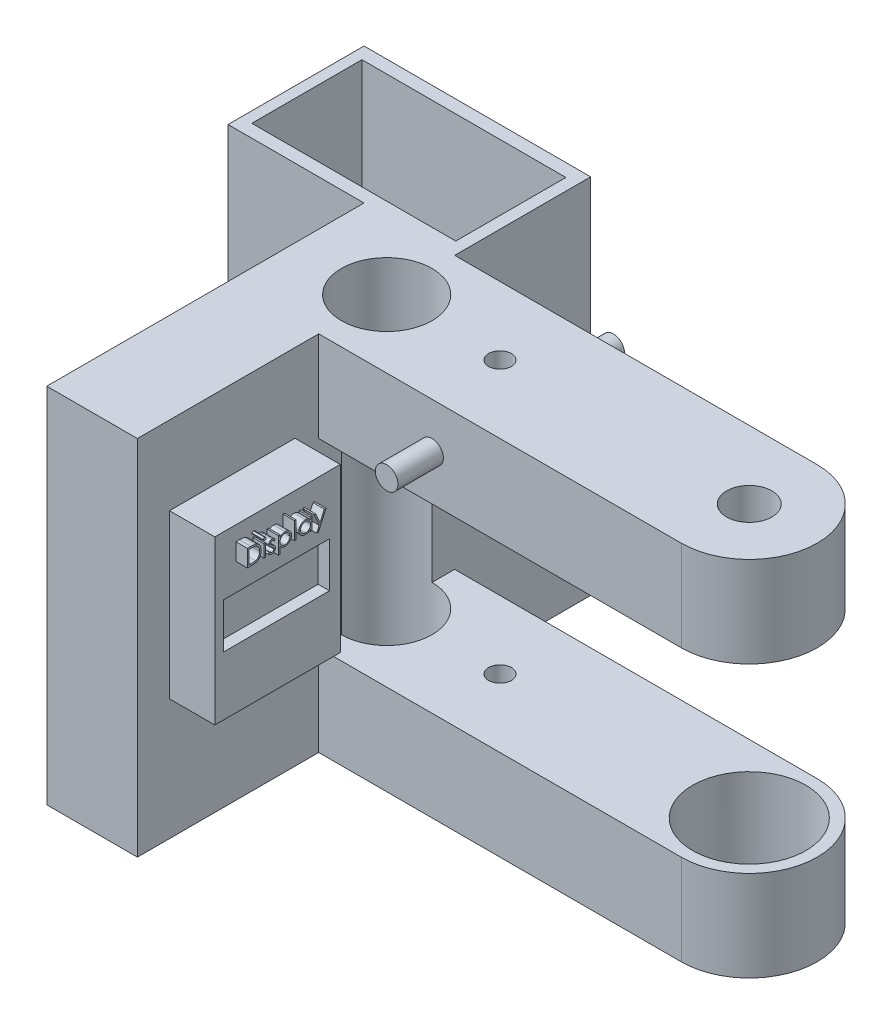
from build123d import *

# Parameters (mm, degrees)
BOSS_EXTRUDE1_DEPTH  = 50.8
SKETCH3_W            = 50.8
SKETCH3_H            = 152.4
BOSS_EXTRUDE2_DEPTH  = 76.2
SKETCH4_W            = 76.2
SKETCH4_H            = 50.8
BOSS_EXTRUDE3_DEPTH  = 254
SKETCH5_R            = 12.7
CUT_EXTRUDE1_DEPTH   = 152.4
SKETCH6_R            = 31.75
CUT_EXTRUDE2_DEPTH   = 254
SKETCH8_R            = 25.4
CUT_EXTRUDE3_DEPTH   = 204.2
SKETCH9_R            = 6.35
CUT_EXTRUDE5_DEPTH   = 204.2
BOSS_EXTRUDE5_DEPTH  = 25.4
BOSS_EXTRUDE6_DEPTH  = 25.4
SKETCH14_W           = 50.8
SKETCH14_H           = 203.2
BOSS_EXTRUDE7_DEPTH  = 101.6
SKETCH15_W           = 70.322125214
SKETCH15_H           = 91.295390628
BOSS_EXTRUDE8_DEPTH  = 25.4
SKETCH16_W           = 0.854807693
SKETCH16_H           = 6.960576923
SKETCH16_W_2         = 0.854807692
SKETCH16_H_2         = 9.769230769
BOSS_EXTRUDE9_DEPTH  = 6.35
SKETCH17_W           = 59.258613474
SKETCH17_H           = 25.299155814
CUT_EXTRUDE6_DEPTH   = 6.35
CUT_EXTRUDE7_DEPTH   = 204.2
SKETCH19_W           = 50.8
SKETCH19_H           = 203.2
BOSS_EXTRUDE10_DEPTH = 76.2
SKETCH20_W           = 76.2
SKETCH20_H           = 203.2
BOSS_EXTRUDE11_DEPTH = 76.2
SKETCH21_W           = 114.3
SKETCH21_H           = 61.717352134
CUT_EXTRUDE9_DEPTH   = 190.5
CUT_EXTRUDE10_DEPTH  = 190.5


with BuildPart() as part:
    # Sketch2 → Boss-Extrude1 (new body)
    with BuildSketch(Plane(origin=(0, 0, 0), x_dir=(1, 0, 0), z_dir=(0, 1, 0))):
        with BuildLine():
            Line((254, 38.1), (0, 38.1))
            Line((0, 38.1), (0, 25.4))
            ThreePointArc((0, 25.4), (17.960512242, 17.960512242), (25.4, 0))
            ThreePointArc((25.4, 0), (17.960512242, -17.960512242), (0, -25.4))
            Line((0, -25.4), (0, -38.1))
            Line((0, -38.1), (254, -38.1))
            Line((254, -38.1), (254, 38.1))
        make_face()
        with BuildLine():
            Line((0, 25.4), (0, 38.1))
            Line((0, 38.1), (-50.8, 38.1))
            Line((-50.8, 38.1), (-50.8, -38.1))
            Line((-50.8, -38.1), (0, -38.1))
            Line((0, -38.1), (0, -25.4))
            ThreePointArc((0, -25.4), (-25.4, 0), (0, 25.4))
        make_face()
    extrude(amount=BOSS_EXTRUDE1_DEPTH)

    # Sketch3 → Boss-Extrude2 (add)
    with BuildSketch(Plane.XY.offset(38.1)):
        with Locations((-25.4, -76.2)):
            Rectangle(SKETCH3_W, SKETCH3_H)
    extrude(amount=-BOSS_EXTRUDE2_DEPTH)

    # Sketch4 → Boss-Extrude3 (add)
    with BuildSketch(Plane(origin=(0, 0, 0), x_dir=(0, 0, -1), z_dir=(1, 0, 0))):
        with Locations((0, -127)):
            Rectangle(SKETCH4_W, SKETCH4_H)
    extrude(amount=BOSS_EXTRUDE3_DEPTH)

    # Sketch5 → Cut-Extrude1 (cut)
    with BuildSketch(Plane(origin=(0, 50.8, 0), x_dir=(1, 0, 0), z_dir=(0, 1, 0))):
        with Locations((203.2, 0)):
            Circle(SKETCH5_R)
    extrude(amount=-CUT_EXTRUDE1_DEPTH, mode=Mode.SUBTRACT)

    # Sketch6 → Cut-Extrude2 (cut)
    with BuildSketch(Plane(origin=(0, -101.6, 0), x_dir=(1, 0, 0), z_dir=(0, 1, 0))):
        with Locations((203.2, 0)):
            Circle(SKETCH6_R)
    extrude(amount=-CUT_EXTRUDE2_DEPTH, mode=Mode.SUBTRACT)

    # Sketch8 → Cut-Extrude3 (cut, through all)
    with BuildSketch(Plane(origin=(0, 50.8, 0), x_dir=(1, 0, 0), z_dir=(0, 1, 0))):
        Circle(SKETCH8_R)
    extrude(amount=-CUT_EXTRUDE3_DEPTH, mode=Mode.SUBTRACT)

    # Sketch9 → Cut-Extrude5 (cut, through all)
    with BuildSketch(Plane(origin=(0, 50.8, 0), x_dir=(1, 0, 0), z_dir=(0, 1, 0))):
        with Locations((63.5, 0)):
            Circle(SKETCH9_R)
    extrude(amount=-CUT_EXTRUDE5_DEPTH, mode=Mode.SUBTRACT)

    # Sketch11 → Boss-Extrude5 (add)
    with BuildSketch(Plane.XY.offset(38.1)):
        with BuildLine():
            ThreePointArc((69.85, 25.4), (63.5, 31.75), (57.15, 25.4))
            Line((57.15, 25.4), (69.85, 25.4))
        make_face()
        with BuildLine():
            Line((69.85, 25.4), (57.15, 25.4))
            ThreePointArc((57.15, 25.4), (63.5, 19.05), (69.85, 25.4))
        make_face()
    extrude(amount=BOSS_EXTRUDE5_DEPTH)

    # Sketch12 → Boss-Extrude6 (add)
    with BuildSketch(Plane(origin=(0, 0, -38.1), x_dir=(-1, 0, 0), z_dir=(0, 0, -1))):
        with BuildLine():
            ThreePointArc((-69.85, 25.4), (-63.5, 19.05), (-57.15, 25.4))
            Line((-57.15, 25.4), (-69.85, 25.4))
        make_face()
        with BuildLine():
            Line((-69.85, 25.4), (-57.15, 25.4))
            ThreePointArc((-57.15, 25.4), (-63.5, 31.75), (-69.85, 25.4))
        make_face()
    extrude(amount=BOSS_EXTRUDE6_DEPTH)

    # Sketch14 → Boss-Extrude7 (add)
    with BuildSketch(Plane.XY.offset(38.1)):
        with Locations((-25.4, -50.8)):
            Rectangle(SKETCH14_W, SKETCH14_H)
    extrude(amount=BOSS_EXTRUDE7_DEPTH)

    # Sketch15 → Boss-Extrude8 (add)
    with BuildSketch(Plane(origin=(0, 0, 0), x_dir=(0, 0, -1), z_dir=(1, 0, 0))):
        with Locations((-86.564796168, -38.887250842)):
            Rectangle(SKETCH15_W, SKETCH15_H)
    extrude(amount=BOSS_EXTRUDE8_DEPTH)

    # Sketch16 → Boss-Extrude9 (add)
    with BuildSketch(Plane(origin=(25.4, 0, 0), x_dir=(0, 0, -1), z_dir=(1, 0, 0))):
        with BuildLine():
            Line((-109.85696619, -11.072266016), (-109.85696619, -1.547266016))
            Line((-109.85696619, -1.547266016), (-107.933648882, -1.547266016))
            add(Edge.make_bspline(
                [(-107.933648882, -1.547266016), (-107.766365422, -1.548470438), (-107.443174646, -1.550797377), (-106.976143628, -1.565551305), (-106.544024961, -1.591651073), (-106.148239823, -1.629668141), (-105.787701667, -1.676348896), (-105.463420026, -1.734860711), (-105.173718123, -1.803952803), (-104.995547717, -1.86285935), (-104.911293113, -1.890715535)],
                knots=[0, 0, 0, 0, 0.000501851, 0.000969573, 0.001401619, 0.001800325, 0.002162196, 0.002491914, 0.002788554, 0.003054677, 0.003054677, 0.003054677, 0.003054677], degree=3))
            add(Edge.make_bspline(
                [(-104.911293113, -1.890715535), (-104.801089573, -1.932709098), (-104.583181542, -2.01574395), (-104.272919302, -2.172379313), (-103.980840992, -2.349852111), (-103.705380319, -2.54839628), (-103.452829499, -2.773633543), (-103.213322294, -3.01599604), (-102.99665651, -3.284297166), (-102.79824179, -3.572972669), (-102.619346889, -3.878621897), (-102.463846752, -4.200662443), (-102.334704099, -4.537458845), (-102.227498246, -4.888074498), (-102.14300753, -5.253280354), (-102.085362415, -5.633501661), (-102.047341364, -6.027235741), (-102.043520339, -6.294410532), (-102.041581575, -6.429973347)],
                knots=[0, 0, 0, 0, 0.000353608, 0.000699197, 0.00104083, 0.00137821, 0.001716199, 0.002054872, 0.002399359, 0.002749199, 0.003104922, 0.003460788, 0.003820798, 0.004185955, 0.004559938, 0.00494422, 0.005338947, 0.005745524, 0.005745524, 0.005745524, 0.005745524], degree=3))
            add(Edge.make_bspline(
                [(-102.041581575, -6.429973347), (-102.043293265, -6.547705718), (-102.046666329, -6.779709651), (-102.076953967, -7.121632374), (-102.120976667, -7.45341145), (-102.189132662, -7.773466962), (-102.271870931, -8.084603041), (-102.377909085, -8.383503649), (-102.4993814, -8.67291073), (-102.641031427, -8.948911147), (-102.796537624, -9.210395181), (-102.963420368, -9.456890011), (-103.141501661, -9.684878294), (-103.332479633, -9.895050445), (-103.533886347, -10.087089626), (-103.747040418, -10.262600039), (-103.972491864, -10.418147521), (-104.209230902, -10.559844437), (-104.464163797, -10.68345269), (-104.742119261, -10.788037217), (-105.044282681, -10.874705505), (-105.369912378, -10.9470163), (-105.719570985, -11.004376674), (-106.093601314, -11.042820642), (-106.491428695, -11.068818266), (-106.764603695, -11.071094451), (-106.905208378, -11.072266016)],
                knots=[0, 0, 0, 0, 0.000353119, 0.000695857, 0.001029112, 0.001356547, 0.00167685, 0.001994264, 0.002307191, 0.002617805, 0.002924094, 0.003219398, 0.00351025, 0.003791207, 0.004070572, 0.004344443, 0.004618619, 0.00489153, 0.005171436, 0.005467338, 0.005781327, 0.006113701, 0.006467535, 0.006843654, 0.007241303, 0.007663052, 0.007663052, 0.007663052, 0.007663052], degree=3))
            Line((-106.905208378, -11.072266016), (-109.85696619, -11.072266016))
        make_face()
        with BuildLine():
            Line((-109.002158498, -10.095342939), (-107.908844195, -10.095342939))
            add(Edge.make_bspline(
                [(-107.908844195, -10.095342939), (-107.751740557, -10.094667762), (-107.449572727, -10.09336915), (-107.015074892, -10.081973976), (-106.618074534, -10.063354132), (-106.258515284, -10.037296242), (-105.936600153, -10.00281951), (-105.651656377, -9.964379596), (-105.404617995, -9.916489391), (-105.255131456, -9.873079995), (-105.186052729, -9.853020222)],
                knots=[0, 0, 0, 0, 0.000471305, 0.000906491, 0.001303825, 0.001663532, 0.001987817, 0.002274926, 0.002526015, 0.002741726, 0.002741726, 0.002741726, 0.002741726], degree=3))
            add(Edge.make_bspline(
                [(-105.186052729, -9.853020222), (-105.099107543, -9.82239991), (-104.927293856, -9.761890652), (-104.679967475, -9.651515874), (-104.44930734, -9.520772813), (-104.231293629, -9.375442338), (-104.029018945, -9.210398576), (-103.840086171, -9.029230385), (-103.664875698, -8.831015747), (-103.50519776, -8.616000679), (-103.362300161, -8.385523449), (-103.238553458, -8.141849909), (-103.130100361, -7.887649947), (-103.044977906, -7.619020022), (-102.978260494, -7.338361656), (-102.931003736, -7.045655104), (-102.901572236, -6.74095503), (-102.898139296, -6.533712463), (-102.896389267, -6.428065295)],
                knots=[0, 0, 0, 0, 0.000276477, 0.00054635, 0.000811185, 0.001071023, 0.001331471, 0.001593271, 0.001855515, 0.002124171, 0.002395799, 0.002668016, 0.002943365, 0.003223953, 0.003512277, 0.003808081, 0.004112808, 0.004429689, 0.004429689, 0.004429689, 0.004429689], degree=3))
            add(Edge.make_bspline(
                [(-102.896389267, -6.428065295), (-102.897786142, -6.316667752), (-102.900530315, -6.097826293), (-102.935022546, -5.776723044), (-102.985427636, -5.467893559), (-103.058317524, -5.171317184), (-103.151202273, -4.886415312), (-103.267120548, -4.614763645), (-103.399563276, -4.353493251), (-103.557143072, -4.108634442), (-103.729724079, -3.877059623), (-103.921252451, -3.664910889), (-104.128685284, -3.471704972), (-104.349760125, -3.294432985), (-104.590707516, -3.140226839), (-104.845851489, -3.002286657), (-105.118935066, -2.885221981), (-105.308925331, -2.82295879), (-105.40547881, -2.791316497)],
                knots=[0, 0, 0, 0, 0.000334046, 0.000656235, 0.000967722, 0.001272228, 0.001571507, 0.001865644, 0.002157495, 0.002449153, 0.002738032, 0.003023099, 0.00330524, 0.003587735, 0.003871938, 0.004162188, 0.004457073, 0.004761795, 0.004761795, 0.004761795, 0.004761795], degree=3))
            add(Edge.make_bspline(
                [(-105.40547881, -2.791316497), (-105.485355859, -2.769228218), (-105.655196379, -2.722262477), (-105.932345206, -2.67103057), (-106.244262149, -2.625842612), (-106.59233205, -2.587584662), (-106.976158142, -2.560132738), (-107.396035621, -2.539527946), (-107.852145974, -2.52563061), (-108.168328441, -2.524681629), (-108.332431935, -2.524189093)],
                knots=[0, 0, 0, 0, 0.000248523, 0.000528429, 0.000844683, 0.001194039, 0.001578624, 0.00199892, 0.00245514, 0.002947432, 0.002947432, 0.002947432, 0.002947432], degree=3))
            Line((-108.332431935, -2.524189093), (-109.002158498, -2.524189093))
            Line((-109.002158498, -2.524189093), (-109.002158498, -10.095342939))
        make_face(mode=Mode.SUBTRACT)
        with BuildLine():
            add(Edge.make_bspline(
                [(-100.030493834, -1.180919862), (-99.977449611, -1.183380448), (-99.873578833, -1.188198748), (-99.723374297, -1.229459625), (-99.586603429, -1.299399484), (-99.465288313, -1.393233472), (-99.361188536, -1.503585886), (-99.288306745, -1.632203236), (-99.241464439, -1.771155674), (-99.235807799, -1.868079595), (-99.232927729, -1.917428275)],
                knots=[0, 0, 0, 0, 0.000158931, 0.000311217, 0.000463108, 0.000616904, 0.000769513, 0.000914826, 0.001057228, 0.001204939, 0.001204939, 0.001204939, 0.001204939], degree=3))
            add(Edge.make_bspline(
                [(-99.232927729, -1.917428275), (-99.235872749, -1.965495924), (-99.241694707, -2.060519978), (-99.288270564, -2.197063498), (-99.361809654, -2.323893727), (-99.46522156, -2.434031874), (-99.586621117, -2.52781399), (-99.723369598, -2.597767601), (-99.873580069, -2.639024832), (-99.977450029, -2.643843634), (-100.030493834, -2.646304477)],
                knots=[0, 0, 0, 0, 0.000143916, 0.000284504, 0.000428167, 0.000580775, 0.000734572, 0.000886463, 0.001038749, 0.00119768, 0.00119768, 0.00119768, 0.00119768], degree=3))
            add(Edge.make_bspline(
                [(-100.030493834, -2.646304477), (-100.082931069, -2.643937596), (-100.184993295, -2.63933077), (-100.332948773, -2.596958079), (-100.468553448, -2.527790052), (-100.590105164, -2.434645934), (-100.691424475, -2.32321732), (-100.765170632, -2.197140899), (-100.811638921, -2.060500271), (-100.817475375, -1.965489305), (-100.820427729, -1.917428275)],
                knots=[0, 0, 0, 0, 0.000157029, 0.000305637, 0.000457528, 0.000611325, 0.000762652, 0.000906314, 0.001046903, 0.001190819, 0.001190819, 0.001190819, 0.001190819], degree=3))
            add(Edge.make_bspline(
                [(-100.820427729, -1.917428275), (-100.817540057, -1.868086463), (-100.811868488, -1.771176031), (-100.765135801, -1.632124548), (-100.692038752, -1.504267747), (-100.590038076, -1.392619781), (-100.468571302, -1.299423276), (-100.33294416, -1.230269105), (-100.184994514, -1.187892817), (-100.082931483, -1.183286488), (-100.030493834, -1.180919862)],
                knots=[0, 0, 0, 0, 0.000147711, 0.000290114, 0.000435427, 0.000586753, 0.00074055, 0.000892441, 0.001041049, 0.001198078, 0.001198078, 0.001198078, 0.001198078], degree=3))
        make_face()
        with Locations((-100.026677729, -7.591977554)):
            Rectangle(SKETCH16_W, SKETCH16_H)
        with BuildLine():
            Line((-94.226196959, -4.979853155), (-94.806245036, -5.577073708))
            add(Edge.make_bspline(
                [(-94.806245036, -5.577073708), (-94.856293478, -5.519071503), (-94.952780982, -5.407250079), (-95.105810941, -5.257742777), (-95.258275176, -5.132184393), (-95.40808659, -5.026178602), (-95.559012308, -4.946034853), (-95.709281207, -4.887538122), (-95.859048874, -4.851338208), (-95.959159441, -4.846672486), (-96.008318354, -4.8443814)],
                knots=[0, 0, 0, 0, 0.00022976, 0.00044295, 0.000640837, 0.00082185, 0.000992565, 0.001152022, 0.001304761, 0.001452127, 0.001452127, 0.001452127, 0.001452127], degree=3))
            add(Edge.make_bspline(
                [(-96.008318354, -4.8443814), (-96.068569122, -4.84730659), (-96.187134106, -4.85306295), (-96.357021512, -4.910521643), (-96.514729999, -4.99871971), (-96.651228637, -5.123819926), (-96.766855823, -5.267414115), (-96.851257341, -5.427968399), (-96.902871911, -5.600637718), (-96.909416217, -5.720461831), (-96.912735421, -5.781235367)],
                knots=[0, 0, 0, 0, 0.000180177, 0.000354563, 0.000532299, 0.000718801, 0.000906237, 0.001082905, 0.00125982, 0.001441896, 0.001441896, 0.001441896, 0.001441896], degree=3))
            add(Edge.make_bspline(
                [(-96.912735421, -5.781235367), (-96.909712425, -5.836241001), (-96.903674954, -5.94609721), (-96.856739348, -6.108152931), (-96.781992395, -6.266151013), (-96.712132795, -6.362932922), (-96.676136863, -6.412800872)],
                knots=[0, 0, 0, 0, 0.000164801, 0.000329137, 0.000502392, 0.000686557, 0.000686557, 0.000686557, 0.000686557], degree=3))
            add(Edge.make_bspline(
                [(-96.676136863, -6.412800872), (-96.654464784, -6.439428919), (-96.608338494, -6.496103362), (-96.521773893, -6.574763134), (-96.423741224, -6.661691689), (-96.305849108, -6.748605509), (-96.173176668, -6.840131847), (-96.022846901, -6.932666223), (-95.85963057, -7.033262265), (-95.742779757, -7.097064622), (-95.68204131, -7.130228756)],
                knots=[0, 0, 0, 0, 0.000102858, 0.00021892, 0.000350133, 0.000495909, 0.000657857, 0.000833616, 0.001025373, 0.001232939, 0.001232939, 0.001232939, 0.001232939], degree=3))
            add(Edge.make_bspline(
                [(-95.68204131, -7.130228756), (-95.607981504, -7.17171667), (-95.464922345, -7.251857659), (-95.261651314, -7.376253352), (-95.077173724, -7.499891728), (-94.909926514, -7.621450524), (-94.763127734, -7.744330828), (-94.632323487, -7.863822652), (-94.520776365, -7.983536412), (-94.458308893, -8.067174386), (-94.428450565, -8.107151833)],
                knots=[0, 0, 0, 0, 0.000254652, 0.000491903, 0.000714697, 0.000920775, 0.001111819, 0.001288692, 0.001452085, 0.001601693, 0.001601693, 0.001601693, 0.001601693], degree=3))
            add(Edge.make_bspline(
                [(-94.428450565, -8.107151833), (-94.378891916, -8.187885973), (-94.280261005, -8.348561894), (-94.176688151, -8.613134901), (-94.116652689, -8.893742768), (-94.108319075, -9.085691167), (-94.104081575, -9.18329366)],
                knots=[0, 0, 0, 0, 0.000283762, 0.000564738, 0.000847658, 0.001140344, 0.001140344, 0.001140344, 0.001140344], degree=3))
            add(Edge.make_bspline(
                [(-94.104081575, -9.18329366), (-94.106039735, -9.252061837), (-94.109898503, -9.387577041), (-94.136726528, -9.587152542), (-94.182868285, -9.77801873), (-94.245716286, -9.962246612), (-94.33058233, -10.136306298), (-94.430044549, -10.304589233), (-94.549446988, -10.463455159), (-94.685767088, -10.612695472), (-94.835025183, -10.749000256), (-94.994245459, -10.868808302), (-95.163623991, -10.968342748), (-95.341950501, -11.050707723), (-95.529630159, -11.116207768), (-95.726692311, -11.161553657), (-95.932510564, -11.188693814), (-96.072473114, -11.192461567), (-96.143790108, -11.1943814)],
                knots=[0, 0, 0, 0, 0.00020629, 0.000406518, 0.000602741, 0.000794631, 0.000989215, 0.001182607, 0.001380282, 0.00158423, 0.001788177, 0.001985852, 0.002180884, 0.002376383, 0.002574306, 0.0027761, 0.002982002, 0.003195917, 0.003195917, 0.003195917, 0.003195917], degree=3))
            add(Edge.make_bspline(
                [(-96.143790108, -11.1943814), (-96.24003935, -11.191679837), (-96.431200458, -11.186314249), (-96.713928908, -11.135951326), (-96.990210402, -11.057586718), (-97.257954179, -10.94950264), (-97.511172532, -10.813021057), (-97.742850262, -10.649565543), (-97.953792171, -10.464535622), (-98.073856902, -10.322714057), (-98.133889267, -10.251803275)],
                knots=[0, 0, 0, 0, 0.00028852, 0.000573031, 0.000858711, 0.001148898, 0.001437468, 0.001719615, 0.001998021, 0.002276427, 0.002276427, 0.002276427, 0.002276427], degree=3))
            Line((-98.133889267, -10.251803275), (-97.56719756, -9.6068814))
            add(Edge.make_bspline(
                [(-97.56719756, -9.6068814), (-97.513388351, -9.664996867), (-97.409071062, -9.777662485), (-97.242244179, -9.927679441), (-97.072483094, -10.0534129), (-96.901482983, -10.158578194), (-96.726712584, -10.239609826), (-96.549151305, -10.296538286), (-96.369160308, -10.333125694), (-96.248268638, -10.337420877), (-96.187675325, -10.339573708)],
                knots=[0, 0, 0, 0, 0.00023752, 0.000460468, 0.000671884, 0.000870514, 0.001061748, 0.001248201, 0.001428943, 0.001610569, 0.001610569, 0.001610569, 0.001610569], degree=3))
            add(Edge.make_bspline(
                [(-96.187675325, -10.339573708), (-96.105167255, -10.335843106), (-95.943960327, -10.328554136), (-95.713064098, -10.262376907), (-95.499871122, -10.158608966), (-95.314750446, -10.011421324), (-95.15717385, -9.84009223), (-95.043069318, -9.647104519), (-94.971560584, -9.438122055), (-94.963162259, -9.293254146), (-94.958889267, -9.219546665)],
                knots=[0, 0, 0, 0, 0.000247032, 0.000482659, 0.00071476, 0.000954067, 0.001187794, 0.001409333, 0.001622327, 0.001842945, 0.001842945, 0.001842945, 0.001842945], degree=3))
            add(Edge.make_bspline(
                [(-94.958889267, -9.219546665), (-94.961845539, -9.158832631), (-94.967682304, -9.038960899), (-95.013520065, -8.865468899), (-95.085945042, -8.700906071), (-95.157259121, -8.604595674), (-95.193579772, -8.555544261)],
                knots=[0, 0, 0, 0, 0.000181907, 0.00035915, 0.000535064, 0.00071765, 0.00071765, 0.00071765, 0.00071765], degree=3))
            add(Edge.make_bspline(
                [(-95.193579772, -8.555544261), (-95.215412145, -8.530955168), (-95.26297094, -8.477391244), (-95.350206989, -8.400034422), (-95.454660485, -8.316655023), (-95.577506215, -8.228666914), (-95.718991822, -8.137230709), (-95.879690751, -8.042826115), (-96.057401541, -7.940969232), (-96.183051616, -7.873424313), (-96.248733017, -7.838116376)],
                knots=[0, 0, 0, 0, 9.8575e-05, 0.000214731, 0.000349123, 0.000499509, 0.000667807, 0.000854329, 0.001058571, 0.001282269, 0.001282269, 0.001282269, 0.001282269], degree=3))
            add(Edge.make_bspline(
                [(-96.248733017, -7.838116376), (-96.319617087, -7.798549168), (-96.457083922, -7.721815724), (-96.651794763, -7.602301248), (-96.827455777, -7.480742451), (-96.98829377, -7.363958224), (-97.130246221, -7.245791226), (-97.252753909, -7.126110278), (-97.360640089, -7.00974203), (-97.420368402, -6.927290101), (-97.448898281, -6.88790604)],
                knots=[0, 0, 0, 0, 0.000243529, 0.000472281, 0.000685035, 0.000884242, 0.001068445, 0.001238466, 0.001397877, 0.001543652, 0.001543652, 0.001543652, 0.001543652], degree=3))
            add(Edge.make_bspline(
                [(-97.448898281, -6.88790604), (-97.498239413, -6.80858833), (-97.59693892, -6.649925193), (-97.692774547, -6.385101681), (-97.758649526, -6.106304775), (-97.764534316, -5.91393555), (-97.767543113, -5.815580319)],
                knots=[0, 0, 0, 0, 0.000279502, 0.000559102, 0.000840564, 0.001135023, 0.001135023, 0.001135023, 0.001135023], degree=3))
            add(Edge.make_bspline(
                [(-97.767543113, -5.815580319), (-97.766089339, -5.751285486), (-97.763244096, -5.625451388), (-97.740536356, -5.440560742), (-97.699193199, -5.264897552), (-97.647336588, -5.095823731), (-97.575264983, -4.936614461), (-97.489142913, -4.785146629), (-97.387939992, -4.641629595), (-97.271345036, -4.508271072), (-97.143147666, -4.387142119), (-97.004641186, -4.281554425), (-96.858940644, -4.191457845), (-96.70542916, -4.115896943), (-96.542632016, -4.058743181), (-96.37168715, -4.01939844), (-96.192940578, -3.993122495), (-96.070745371, -3.990773673), (-96.008318354, -3.989573708)],
                knots=[0, 0, 0, 0, 0.000192864, 0.000377463, 0.000557519, 0.000733722, 0.000907114, 0.001080589, 0.001255819, 0.00143298, 0.001611156, 0.001784032, 0.001954534, 0.00212435, 0.00229634, 0.00247082, 0.002649994, 0.002837139, 0.002837139, 0.002837139, 0.002837139], degree=3))
            add(Edge.make_bspline(
                [(-96.008318354, -3.989573708), (-95.934317095, -3.992579092), (-95.784926392, -3.998646239), (-95.560804159, -4.046831011), (-95.337011993, -4.126114673), (-95.112974876, -4.235614708), (-94.890334017, -4.377310992), (-94.667131, -4.548568585), (-94.440686289, -4.748260794), (-94.299290894, -4.900930829), (-94.226196959, -4.979853155)],
                knots=[0, 0, 0, 0, 0.00022186, 0.000447882, 0.000684434, 0.00093276, 0.001194274, 0.001474764, 0.001776146, 0.002098675, 0.002098675, 0.002098675, 0.002098675], degree=3))
        make_face()
        with BuildLine():
            Line((-92.39446619, -4.111689093), (-91.539658498, -4.111689093))
            Line((-91.539658498, -4.111689093), (-91.539658498, -5.39962479))
            add(Edge.make_bspline(
                [(-91.539658498, -5.39962479), (-91.448878488, -5.282772814), (-91.272465705, -5.055694384), (-90.968414357, -4.761806963), (-90.64748497, -4.513952029), (-90.301418826, -4.319689565), (-89.935594355, -4.173220069), (-89.551512834, -4.064963138), (-89.145914481, -4.001168839), (-88.868610563, -3.99348989), (-88.727188546, -3.989573708)],
                knots=[0, 0, 0, 0, 0.000443428, 0.000861714, 0.001264707, 0.001656866, 0.002048036, 0.002444323, 0.002851816, 0.003275924, 0.003275924, 0.003275924, 0.003275924], degree=3))
            add(Edge.make_bspline(
                [(-88.727188546, -3.989573708), (-88.60365854, -3.993147431), (-88.359494994, -4.000211081), (-88.00009435, -4.048034894), (-87.653995627, -4.129998042), (-87.323156852, -4.248110534), (-87.004033796, -4.394130062), (-86.701350796, -4.578417138), (-86.410393191, -4.791793986), (-86.138478419, -5.037354339), (-85.887232412, -5.303042693), (-85.669936733, -5.588853392), (-85.482506765, -5.885387288), (-85.331004029, -6.197241481), (-85.212327027, -6.521960243), (-85.127922797, -6.8608555), (-85.077691639, -7.212670738), (-85.070952152, -7.451891713), (-85.067543113, -7.572897025)],
                knots=[0, 0, 0, 0, 0.00037056, 0.000732432, 0.001085546, 0.001435558, 0.00178471, 0.002136481, 0.002496734, 0.002865621, 0.003234152, 0.003592119, 0.003941006, 0.004284905, 0.004630173, 0.004976326, 0.005330895, 0.005693832, 0.005693832, 0.005693832, 0.005693832], degree=3))
            add(Edge.make_bspline(
                [(-85.067543113, -7.572897025), (-85.070878185, -7.696456165), (-85.077455427, -7.940132619), (-85.128468621, -8.297965363), (-85.209994115, -8.642191716), (-85.327173884, -8.972239126), (-85.478598221, -9.287880348), (-85.662851346, -9.588887755), (-85.88025666, -9.875164904), (-86.128726157, -10.142825296), (-86.398291647, -10.389384855), (-86.686429672, -10.605025602), (-86.988668606, -10.786113202), (-87.303462146, -10.937378256), (-87.633505134, -11.051384842), (-87.977257697, -11.133620428), (-88.334532681, -11.184332878), (-88.577559388, -11.191006208), (-88.700475806, -11.1943814)],
                knots=[0, 0, 0, 0, 0.00037056, 0.000730799, 0.001082057, 0.00143027, 0.001779323, 0.002130452, 0.002487263, 0.002855892, 0.003224641, 0.003581829, 0.0039336, 0.00428011, 0.00462769, 0.004978948, 0.005339186, 0.00570784, 0.00570784, 0.00570784, 0.00570784], degree=3))
            add(Edge.make_bspline(
                [(-88.700475806, -11.1943814), (-88.838799412, -11.190857674), (-89.112029088, -11.18389728), (-89.511528463, -11.113359457), (-89.896003324, -11.007939654), (-90.261194068, -10.853637393), (-90.609993615, -10.656999167), (-90.940428944, -10.417213535), (-91.25425525, -10.134781978), (-91.443146225, -9.920518964), (-91.539658498, -9.811043059)],
                knots=[0, 0, 0, 0, 0.000414579, 0.000818915, 0.001213366, 0.00160848, 0.002004901, 0.002412144, 0.002830952, 0.003268499, 0.003268499, 0.003268499, 0.003268499], degree=3))
            Line((-91.539658498, -9.811043059), (-91.539658498, -13.636689093))
            Line((-91.539658498, -13.636689093), (-92.39446619, -13.636689093))
            Line((-92.39446619, -13.636689093), (-92.39446619, -4.111689093))
        make_face()
        with BuildLine():
            add(Edge.make_bspline(
                [(-88.734820757, -4.8443814), (-88.831647995, -4.846123817), (-89.022275869, -4.849554187), (-89.301690979, -4.890304719), (-89.570827822, -4.949462429), (-89.82697399, -5.039029815), (-90.072584596, -5.148972299), (-90.30576793, -5.286355487), (-90.526360311, -5.44869416), (-90.733806729, -5.63287866), (-90.921213263, -5.835828347), (-91.087119517, -6.052420885), (-91.22647654, -6.282381979), (-91.342142753, -6.523569573), (-91.430162686, -6.777874242), (-91.492635038, -7.043847655), (-91.531906212, -7.321780929), (-91.53704682, -7.511072633), (-91.539658498, -7.607241977)],
                knots=[0, 0, 0, 0, 0.00029025, 0.000571427, 0.000845444, 0.001115769, 0.001383903, 0.001651588, 0.001925983, 0.002204389, 0.002482533, 0.002753483, 0.003021488, 0.003287769, 0.003554488, 0.003827079, 0.004106366, 0.004394791, 0.004394791, 0.004394791, 0.004394791], degree=3))
            add(Edge.make_bspline(
                [(-91.539658498, -7.607241977), (-91.535329097, -7.733483912), (-91.526847433, -7.980802554), (-91.457893596, -8.342165057), (-91.34567477, -8.684117063), (-91.186393056, -9.003778885), (-90.985150015, -9.297646458), (-90.742675747, -9.560783037), (-90.461164233, -9.791534574), (-90.145295661, -9.985902414), (-89.80668972, -10.143712795), (-89.45348663, -10.256690753), (-89.090543633, -10.326283746), (-88.845156992, -10.335119732), (-88.721464387, -10.339573708)],
                knots=[0, 0, 0, 0, 0.000378488, 0.000741489, 0.001099294, 0.001455124, 0.00180919, 0.002164339, 0.002524936, 0.00289769, 0.003274162, 0.003642851, 0.004007729, 0.004378598, 0.004378598, 0.004378598, 0.004378598], degree=3))
            add(Edge.make_bspline(
                [(-88.721464387, -10.339573708), (-88.600263476, -10.33533814), (-88.359701456, -10.326931298), (-88.005485425, -10.25416523), (-87.661250188, -10.143008413), (-87.334188433, -9.980921334), (-87.027147369, -9.782284105), (-86.749883999, -9.543995729), (-86.507658041, -9.267798098), (-86.301198618, -8.960253529), (-86.134833647, -8.630483378), (-86.00983778, -8.289266885), (-85.937696591, -7.937806841), (-85.92747276, -7.701048779), (-85.922350806, -7.58243729)],
                knots=[0, 0, 0, 0, 0.000363252, 0.000720991, 0.001080607, 0.001445838, 0.001812592, 0.002175182, 0.00253884, 0.002911399, 0.003283445, 0.003644365, 0.003998734, 0.004354497, 0.004354497, 0.004354497, 0.004354497], degree=3))
            add(Edge.make_bspline(
                [(-85.922350806, -7.58243729), (-85.92630976, -7.463089069), (-85.934196824, -7.225322472), (-86.011885548, -6.874903428), (-86.128634773, -6.532308294), (-86.298884764, -6.207041655), (-86.500818219, -5.900135044), (-86.745058261, -5.629206273), (-87.018878053, -5.391977514), (-87.325553563, -5.19599272), (-87.654684292, -5.040094337), (-88.001162742, -4.926111006), (-88.363231403, -4.857602445), (-88.609868091, -4.848827181), (-88.734820757, -4.8443814)],
                knots=[0, 0, 0, 0, 0.00035754, 0.000712294, 0.00107194, 0.001440585, 0.001810496, 0.0021713, 0.002531199, 0.002894276, 0.003259573, 0.003621001, 0.003985879, 0.004360557, 0.004360557, 0.004360557, 0.004360557], degree=3))
        make_face(mode=Mode.SUBTRACT)
        with Locations((-83.052639267, -6.187650632)):
            Rectangle(SKETCH16_W_2, SKETCH16_H_2)
        with BuildLine():
            Line((-73.588696959, -4.111689093), (-73.588696959, -11.072266016))
            Line((-73.588696959, -11.072266016), (-74.443504652, -11.072266016))
            Line((-74.443504652, -11.072266016), (-74.443504652, -9.868284646))
            add(Edge.make_bspline(
                [(-74.443504652, -9.868284646), (-74.53989436, -9.977249541), (-74.728000089, -10.189895903), (-75.042164846, -10.467705244), (-75.375181102, -10.697334819), (-75.725432554, -10.882799947), (-76.092602916, -11.022115472), (-76.475878268, -11.121137805), (-76.875414955, -11.184802456), (-77.148244577, -11.191159773), (-77.28650345, -11.1943814)],
                knots=[0, 0, 0, 0, 0.000436143, 0.00085114, 0.001254439, 0.001647053, 0.002037202, 0.002429654, 0.002833084, 0.003247571, 0.003247571, 0.003247571, 0.003247571], degree=3))
            add(Edge.make_bspline(
                [(-77.28650345, -11.1943814), (-77.40942481, -11.191043916), (-77.651831175, -11.184462249), (-78.008417449, -11.133401979), (-78.351568499, -11.051403645), (-78.681608586, -10.937373367), (-78.996402068, -10.786114131), (-79.298644188, -10.605026877), (-79.586769157, -10.389378618), (-79.856385274, -10.14284977), (-80.104666646, -9.87507484), (-80.322547681, -9.589473031), (-80.50421142, -9.287279332), (-80.656121782, -8.972319821), (-80.773133262, -8.642169932), (-80.854704367, -8.297971354), (-80.905705154, -7.940131055), (-80.912284101, -7.696455639), (-80.915620036, -7.572897025)],
                knots=[0, 0, 0, 0, 0.000368654, 0.000727003, 0.001078261, 0.001425841, 0.001772351, 0.002124121, 0.00248131, 0.002850058, 0.003218688, 0.003575499, 0.003925635, 0.004274689, 0.004622902, 0.00497416, 0.005334398, 0.005704959, 0.005704959, 0.005704959, 0.005704959], degree=3))
            add(Edge.make_bspline(
                [(-80.915620036, -7.572897025), (-80.912210164, -7.451892232), (-80.905469031, -7.212672283), (-80.855249911, -6.860849541), (-80.770801238, -6.521981989), (-80.652288881, -6.197160593), (-80.500318989, -5.885992314), (-80.315457552, -5.588257074), (-80.09769122, -5.303134643), (-79.846632884, -5.037329375), (-79.574667545, -4.791800418), (-79.28372307, -4.578415801), (-78.981036855, -4.394129234), (-78.661913947, -4.248115131), (-78.331077755, -4.129980354), (-77.98558302, -4.048247776), (-77.626867224, -4.00008578), (-77.383325242, -3.993111401), (-77.259790709, -3.989573708)],
                knots=[0, 0, 0, 0, 0.000362937, 0.000717506, 0.001063659, 0.001408926, 0.001752826, 0.002100705, 0.002458672, 0.002827203, 0.003196089, 0.003556342, 0.003908113, 0.004257266, 0.004607278, 0.004960391, 0.005320372, 0.005690932, 0.005690932, 0.005690932, 0.005690932], degree=3))
            add(Edge.make_bspline(
                [(-77.259790709, -3.989573708), (-77.117732521, -3.993486446), (-76.83916312, -4.001159141), (-76.431689037, -4.065011277), (-76.046213708, -4.172884535), (-75.679761507, -4.319617154), (-75.333648354, -4.514604053), (-75.011150947, -4.760566661), (-74.708894168, -5.055953748), (-74.533687802, -5.282840458), (-74.443504652, -5.39962479)],
                knots=[0, 0, 0, 0, 0.000426013, 0.000835392, 0.001233517, 0.001624686, 0.002016846, 0.002421357, 0.002838279, 0.003280503, 0.003280503, 0.003280503, 0.003280503], degree=3))
            Line((-74.443504652, -5.39962479), (-74.443504652, -4.111689093))
            Line((-74.443504652, -4.111689093), (-73.588696959, -4.111689093))
        make_face()
        with BuildLine():
            add(Edge.make_bspline(
                [(-77.248342392, -4.8443814), (-77.373294983, -4.848827229), (-77.619931523, -4.857602587), (-77.982001271, -4.926110456), (-78.328475634, -5.040096388), (-78.657621736, -5.19598499), (-78.96424024, -5.392006052), (-79.238270873, -5.629100674), (-79.481954939, -5.900799976), (-79.686901, -6.205877863), (-79.853970853, -6.532933953), (-79.971446847, -6.874811888), (-80.04892387, -7.225345434), (-80.056839201, -7.463096744), (-80.060812344, -7.58243729)],
                knots=[0, 0, 0, 0, 0.000374679, 0.000739556, 0.001100985, 0.001466281, 0.001829358, 0.002189257, 0.002550061, 0.002921039, 0.003288818, 0.003648465, 0.004003219, 0.004360759, 0.004360759, 0.004360759, 0.004360759], degree=3))
            add(Edge.make_bspline(
                [(-80.060812344, -7.58243729), (-80.05573717, -7.701064653), (-80.045606715, -7.9378544), (-79.972806611, -8.288865827), (-79.850669241, -8.630824327), (-79.684003342, -8.960827459), (-79.47530617, -9.267217047), (-79.233402052, -9.544095523), (-78.955951643, -9.782192188), (-78.648627499, -9.981503014), (-78.320401522, -10.142509588), (-77.975232037, -10.254538936), (-77.619607622, -10.326868467), (-77.377802342, -10.335317079), (-77.255974604, -10.339573708)],
                knots=[0, 0, 0, 0, 0.000355764, 0.000710133, 0.001070411, 0.001442457, 0.001816085, 0.002179743, 0.002542333, 0.002909087, 0.003276034, 0.00363565, 0.003995261, 0.004360417, 0.004360417, 0.004360417, 0.004360417], degree=3))
            add(Edge.make_bspline(
                [(-77.255974604, -10.339573708), (-77.132295192, -10.335056235), (-76.886309111, -10.326071429), (-76.523165198, -10.257270271), (-76.170753907, -10.14359947), (-75.833875807, -9.986031132), (-75.520051193, -9.790748613), (-75.238389111, -9.562129316), (-75.000220655, -9.296237079), (-74.798310767, -9.004019732), (-74.639990526, -8.683674941), (-74.524667108, -8.342586894), (-74.456484693, -7.980743715), (-74.447891157, -7.733464028), (-74.443504652, -7.607241977)],
                knots=[0, 0, 0, 0, 0.00037087, 0.000737623, 0.001104496, 0.001479237, 0.001850372, 0.002210969, 0.002563546, 0.002917612, 0.003273442, 0.003631851, 0.003994853, 0.004373341, 0.004373341, 0.004373341, 0.004373341], degree=3))
            add(Edge.make_bspline(
                [(-74.443504652, -7.607241977), (-74.446116288, -7.511072596), (-74.451256815, -7.321780819), (-74.490528579, -7.043848075), (-74.552998771, -6.777872721), (-74.641026563, -6.523575117), (-74.756663558, -6.282361253), (-74.896130692, -6.052499163), (-75.061880523, -5.835184352), (-75.251244861, -5.63340928), (-75.458523019, -5.449368694), (-75.677855305, -5.285091724), (-75.911840323, -5.150139422), (-76.156543116, -5.038448533), (-76.412388248, -4.949568989), (-76.681457578, -4.890275337), (-76.960891106, -4.849561892), (-77.151516443, -4.846126412), (-77.248342392, -4.8443814)],
                knots=[0, 0, 0, 0, 0.000288425, 0.000567712, 0.000840304, 0.001107022, 0.001373303, 0.001641308, 0.001912258, 0.002191702, 0.002470107, 0.002742966, 0.003012299, 0.003278696, 0.003549021, 0.003823037, 0.004104215, 0.004394465, 0.004394465, 0.004394465, 0.004394465], degree=3))
        make_face(mode=Mode.SUBTRACT)
        Polygon((-72.367543113, -4.111689093), (-71.44595357, -4.111689093), (-69.089508257, -9.442788852), (-66.69680994, -4.111689093), (-65.773312344, -4.111689093), (-70.047350806, -13.636689093), (-70.970848402, -13.636689093), (-69.553165108, -10.478861569), align=None)
    extrude(amount=BOSS_EXTRUDE9_DEPTH)

    # Sketch17 → Cut-Extrude6 (cut)
    with BuildSketch(Plane(origin=(25.4, 0, 0), x_dir=(0, 0, -1), z_dir=(1, 0, 0))):
        with Locations((-87.087446887, -38.887250842)):
            Rectangle(SKETCH17_W, SKETCH17_H)
    extrude(amount=-CUT_EXTRUDE6_DEPTH, mode=Mode.SUBTRACT)

    # Sketch18 → Cut-Extrude7 (cut, through all)
    with BuildSketch(Plane.XZ.offset(152.4)):
        with BuildLine():
            Line((203.2, -38.1), (254, -38.1))
            Line((254, -38.1), (254, 38.1))
            Line((254, 38.1), (203.2, 38.1))
            ThreePointArc((203.2, 38.1), (241.3, 0), (203.2, -38.1))
        make_face()
    extrude(amount=-CUT_EXTRUDE7_DEPTH, mode=Mode.SUBTRACT)

    # Sketch19 → Boss-Extrude10 (add)
    with BuildSketch(Plane(origin=(0, 0, -38.1), x_dir=(-1, 0, 0), z_dir=(0, 0, -1))):
        with Locations((25.4, -50.8)):
            Rectangle(SKETCH19_W, SKETCH19_H)
    extrude(amount=BOSS_EXTRUDE10_DEPTH)

    # Sketch20 → Boss-Extrude11 (add)
    with BuildSketch(Plane.ZY.offset(50.8)):
        with Locations((-76.2, -50.8)):
            Rectangle(SKETCH20_W, SKETCH20_H)
    extrude(amount=BOSS_EXTRUDE11_DEPTH)

    # Sketch21 → Cut-Extrude9 (cut)
    with BuildSketch(Plane(origin=(0, 50.8, 0), x_dir=(1, 0, 0), z_dir=(0, 1, 0))):
        with Locations((-63.779012952, 76.2)):
            Rectangle(SKETCH21_W, SKETCH21_H)
    extrude(amount=-CUT_EXTRUDE9_DEPTH, mode=Mode.SUBTRACT)

    # Sketch22 → Cut-Extrude10 (cut)
    with BuildSketch(Plane(origin=(0, -139.7, 0), x_dir=(1, 0, 0), z_dir=(0, 1, 0))):
        with BuildLine():
            ThreePointArc((-70.129012952, 76.2), (-63.779012952, 69.85), (-57.429012952, 76.2))
            Line((-57.429012952, 76.2), (-70.129012952, 76.2))
        make_face()
        with BuildLine():
            Line((-70.129012952, 76.2), (-57.429012952, 76.2))
            ThreePointArc((-57.429012952, 76.2), (-63.779012952, 82.55), (-70.129012952, 76.2))
        make_face()
    extrude(amount=-CUT_EXTRUDE10_DEPTH, mode=Mode.SUBTRACT)


solid = part.part
